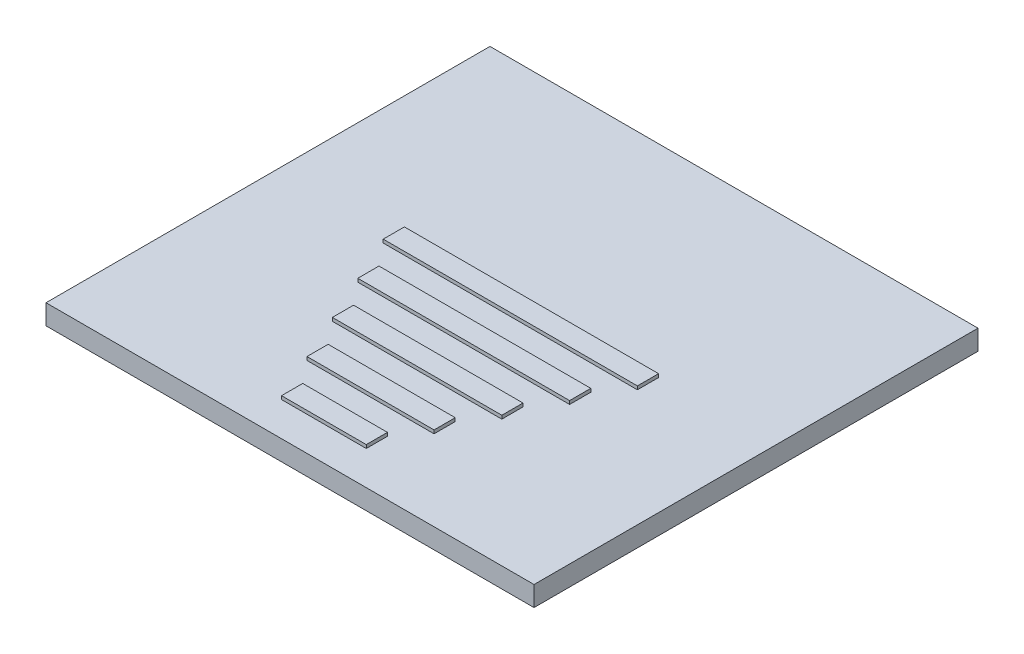
from build123d import *

# Parameters (mm, degrees)
SKETCH1_W           = 36.576
SKETCH1_H           = 33.274
BOSS_EXTRUDE1_DEPTH = 1.499997
SKETCH2_W           = 19.05
SKETCH2_H           = 1.5875
SKETCH2_W_2         = 12.7
SKETCH2_W_3         = 9.525
SKETCH2_W_4         = 6.35
SKETCH2_W_5         = 15.875
BOSS_EXTRUDE2_DEPTH = 0.254


with BuildPart() as part:
    # Sketch1 → Boss-Extrude1 (new body)
    with BuildSketch(Plane(origin=(0, 0, 0), x_dir=(1, 0, 0), z_dir=(0, 1, 0))):
        Rectangle(SKETCH1_W, SKETCH1_H)
    extrude(amount=BOSS_EXTRUDE1_DEPTH)

    # Sketch2 → Boss-Extrude2 (add)
    with BuildSketch(Plane(origin=(0, 1.499997, 0), x_dir=(1, 0, 0), z_dir=(0, 1, 0))):
        with Locations((0, 0.66675)):
            Rectangle(SKETCH2_W, SKETCH2_H)
        with Locations((0, -6.31825)):
            Rectangle(SKETCH2_W_2, SKETCH2_H)
        with Locations((0, -9.81075)):
            Rectangle(SKETCH2_W_3, SKETCH2_H)
        with Locations((0, -13.30325)):
            Rectangle(SKETCH2_W_4, SKETCH2_H)
        with Locations((0, -2.82575)):
            Rectangle(SKETCH2_W_5, SKETCH2_H)
    extrude(amount=BOSS_EXTRUDE2_DEPTH)


solid = part.part
